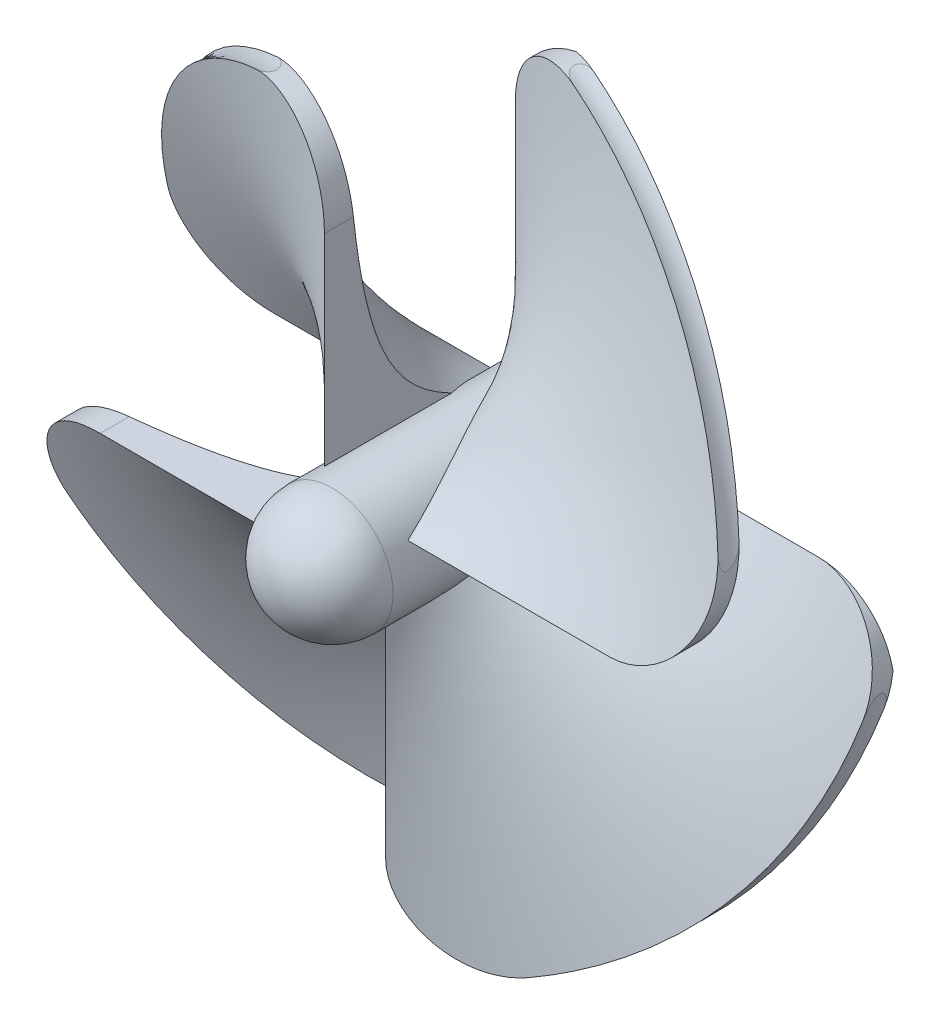
from build123d import *

# Parameters (mm, degrees)
SWEEP1_PITCH        = 31.75
SWEEP1_HEIGHT       = 7.9375
SWEEP1_RADIUS       = 1.905
SWEEP1_START_ANGLE  = -180
SKETCH4_W           = 12.7
SKETCH4_H           = 2.54
SKETCH6_W           = 25.4
SKETCH6_H           = 38.1
CUT_EXTRUDE3_DEPTH  = 8.9375001
SKETCH1_2_R         = 1.905
BOSS_EXTRUDE1_DEPTH = 3.175
SKETCH7_R           = 2.54
BOSS_EXTRUDE2_DEPTH = 8.89
CIRPATTERN1_COUNT   = 4
CUT_EXTRUDE5_DEPTH  = 3.81


with BuildPart() as part:
    # Sweep1: sweep along a helix
    with BuildLine() as sweep1_path:
        add(Helix(SWEEP1_PITCH, SWEEP1_HEIGHT, SWEEP1_RADIUS, center=(0, 0, 0), direction=(0, 0, 1), lefthand=True, mode=Mode.PRIVATE).rotate(Axis((0, 0, 0), (0, 0, 1)), SWEEP1_START_ANGLE))
    # Sketch4 → Sweep1 (sweep)
    with BuildSketch(Plane.XY):
        with Locations((-8.255, 0)):
            Rectangle(SKETCH4_W, SKETCH4_H)
    sweep(path=sweep1_path.line, is_frenet=True)

    # Sketch6 → Cut-Extrude3 (cut, through all)
    with BuildSketch(Plane.XY):
        with Locations((-8.89, -2.46391355)):
            Rectangle(SKETCH6_W, SKETCH6_H)
        with BuildLine():
            Line((-11.326023348, -1.27), (-1.905, -1.27))
            add(Edge.make_bspline(
                [(-1.905, -1.27), (-2.072198672, -1.019201992), (-2.168788886, -0.733675518), (-2.265379101, -0.448149045), (-2.284778394, -0.147352263), (-2.304177688, 0.153444519), (-2.24506403, 0.449012806), (-2.185950373, 0.744581093), (-2.052352263, 1.014778394), (-1.918754153, 1.284975696), (-1.71977608, 1.511388512), (-1.520798008, 1.737801328), (-1.27, 1.905)],
                knots=[0, 0, 0, 0.041666667, 0.041666667, 0.083333333, 0.083333333, 0.125, 0.125, 0.166666667, 0.166666667, 0.208333333, 0.208333333, 0.25, 0.25, 0.25], degree=2, weights=[1, 0.991444861, 1, 0.991444861, 1, 0.991444861, 1, 0.991444861, 1, 0.991444861, 1, 0.991444861, 1]))
            Line((-1.27, 1.905), (-1.27, 10.590080495))
            ThreePointArc((-1.27, 10.590080495), (-2.687275058, 13.234135719), (-5.673797183, 13.517653292))
            add(Edge.make_bspline(
                [(-14.457043728, 2.431627364), (-14.446801605, 2.492521079), (-14.43604688, 2.553326354), (-14.099895089, 4.453867981), (-13.283301022, 6.202647737), (-12.466706956, 7.951427493), (-11.225320151, 9.429268927), (-9.983933347, 10.907110361), (-8.402352263, 12.013301022), (-7.118461613, 12.91128081), (-5.673797183, 13.517653292)],
                knots=[0.040322466, 0.040322466, 0.040322466, 0.041666667, 0.041666667, 0.083333333, 0.083333333, 0.125, 0.125, 0.166666667, 0.166666667, 0.200545249, 0.200545249, 0.200545249], degree=2, weights=[0.999465816, 0.999724004, 1, 0.991444861, 1, 0.991444861, 1, 0.991444861, 1, 0.993043937, 0.997399628]))
            ThreePointArc((-14.457043728, 2.431627364), (-13.750138329, -0.145436919), (-11.326023348, -1.27))
        make_face(mode=Mode.SUBTRACT)
    extrude(amount=CUT_EXTRUDE3_DEPTH, mode=Mode.SUBTRACT)



with BuildPart() as body_2:
    # Sketch1_2 → Boss-Extrude1 (new body)
    with BuildSketch(Plane.XY):
        Circle(SKETCH1_2_R)
    extrude(amount=BOSS_EXTRUDE1_DEPTH)


with BuildPart() as part_1:
    add(part.part)

    add(body_2.part)  # Boss-Extrude2 merges body 2
    # Sketch7 → Boss-Extrude2 (add)
    with BuildSketch(Plane.XY):
        Circle(SKETCH7_R)
    extrude(amount=BOSS_EXTRUDE2_DEPTH)


with BuildPart() as cirpattern1_1:
    # CirPattern1: pattern copy
    add(part_1.part.rotate(Axis((0, 0, 0), (0, 0, 1)), 1 * 360 / CIRPATTERN1_COUNT))


with BuildPart() as cirpattern1_2:
    # CirPattern1: pattern copy
    add(part_1.part.rotate(Axis((0, 0, 0), (0, 0, 1)), 2 * 360 / CIRPATTERN1_COUNT))


with BuildPart() as cirpattern1_3:
    # CirPattern1: pattern copy
    add(part_1.part.rotate(Axis((0, 0, 0), (0, 0, 1)), 3 * 360 / CIRPATTERN1_COUNT))


with BuildPart() as part_2:
    add(part_1.part)

    add(cirpattern1_1.part)  # Revolve1 merges CirPattern1_1

    add(cirpattern1_2.part)  # Revolve1 merges CirPattern1_2

    add(cirpattern1_3.part)  # Revolve1 merges CirPattern1_3
    # Sketch10 → Revolve1 (revolve)
    with BuildSketch(Plane.XY.offset(8.89)):
        with BuildLine():
            Line((0, 2.54), (0, -2.54))
            ThreePointArc((0, -2.54), (2.54, 0), (0, 2.54))
        make_face()
    revolve(axis=Axis((0, 2.54, 8.89), (0, -1, 0)))

    # Sketch11 → Cut-Extrude5 (cut)
    with BuildSketch(Plane(origin=(0, 0, 0), x_dir=(-1, 0, 0), z_dir=(0, 0, -1))):
        with BuildLine():
            ThreePointArc((0.375, 0.927024811), (0, 1), (-0.375, 0.927024811))
            Line((-0.375, 0.927024811), (-0.375, 0.272607516))
            Line((-0.375, 0.272607516), (0.375, 0.272607516))
            Line((0.375, 0.272607516), (0.375, 0.927024811))
        make_face()
        with BuildLine():
            Line((-0.375, 0.272607516), (-0.375, 0.927024811))
            ThreePointArc((-0.375, 0.927024811), (-0.559016994, -0.829156198), (1, 0))
            ThreePointArc((1, 0), (0.829156198, 0.559016994), (0.375, 0.927024811))
            Line((0.375, 0.927024811), (0.375, 0.272607516))
            Line((0.375, 0.272607516), (-0.375, 0.272607516))
        make_face()
        with BuildLine():
            Line((0.375, 1.522607516), (-0.375, 1.522607516))
            Line((-0.375, 1.522607516), (-0.375, 0.927024811))
            ThreePointArc((-0.375, 0.927024811), (0, 1), (0.375, 0.927024811))
            Line((0.375, 0.927024811), (0.375, 1.522607516))
        make_face()
    extrude(amount=-CUT_EXTRUDE5_DEPTH, mode=Mode.SUBTRACT)


solid = part_2.part
